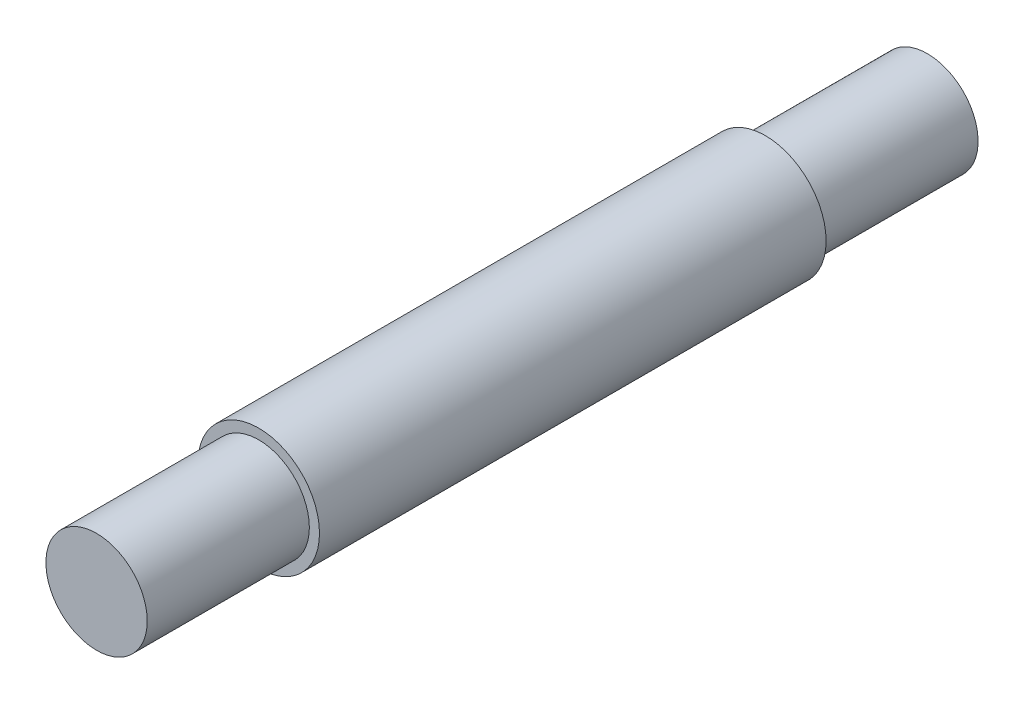
from build123d import *

# Parameters (mm, degrees)
IZIM1_R                     = 6
Y_KSEKLIK_EKSTR_ZYON1_DEPTH = 50
IZIM2_R                     = 5
Y_KSEKLIK_EKSTR_ZYON2_DEPTH = 16
IZIM3_R                     = 5
Y_KSEKLIK_EKSTR_ZYON3_DEPTH = 16


with BuildPart() as part:
    # Çizim1 → Yükseklik-Ekstrüzyon1 (new body)
    with BuildSketch(Plane.XY):
        Circle(IZIM1_R)
    extrude(amount=Y_KSEKLIK_EKSTR_ZYON1_DEPTH)

    # Çizim2 → Yükseklik-Ekstrüzyon2 (add)
    with BuildSketch(Plane.XY.offset(50)):
        Circle(IZIM2_R)
    extrude(amount=Y_KSEKLIK_EKSTR_ZYON2_DEPTH)

    # Çizim3 → Yükseklik-Ekstrüzyon3 (add)
    with BuildSketch(Plane(origin=(0, 0, 0), x_dir=(-1, 0, 0), z_dir=(0, 0, -1))):
        Circle(IZIM3_R)
    extrude(amount=Y_KSEKLIK_EKSTR_ZYON3_DEPTH)


solid = part.part
